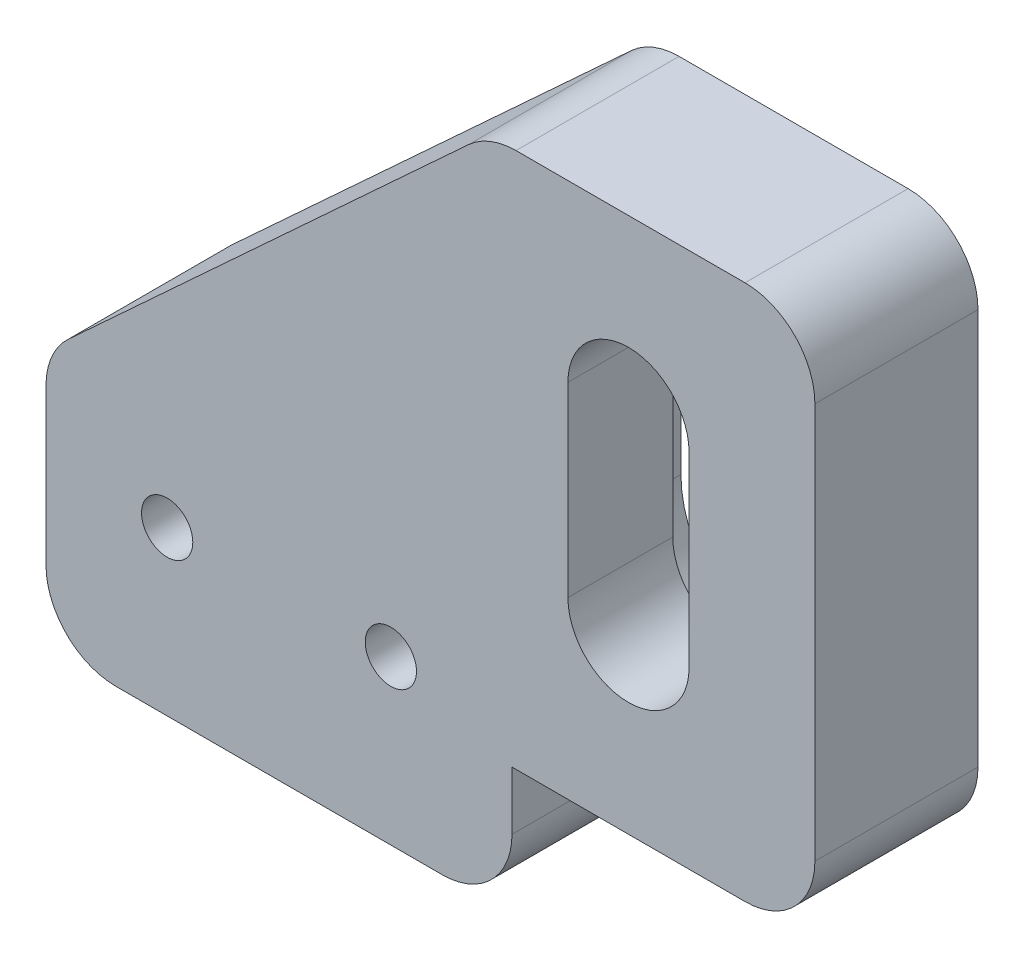
from build123d import *

# Parameters (mm, degrees)
SKETCH1_R           = 1.1
BOSS_EXTRUDE1_DEPTH = 7
CUT_EXTRUDE1_DEPTH  = 2.5


with BuildPart() as part:
    # Sketch1 → Boss-Extrude1 (new body)
    with BuildSketch(Plane.XY):
        with BuildLine():
            Line((3, 0), (17, 0))
            ThreePointArc((17, 0), (19.121320344, 0.878679656), (20, 3))
            Line((20, 3), (20, 5.5))
            Line((20, 5.5), (30, 5.5))
            ThreePointArc((30, 5.5), (32.121320344, 6.378679656), (33, 8.5))
            Line((33, 8.5), (33, 25.5))
            ThreePointArc((33, 25.5), (32.121320344, 27.621320344), (30, 28.5))
            Line((30, 28.5), (20.171059892, 28.5))
            ThreePointArc((20.171059892, 28.5), (19.080167127, 28.294629309), (18.138632628, 27.706635315))
            Line((18.138632628, 27.706635315), (0.967572736, 11.891185415))
            ThreePointArc((0.967572736, 11.891185415), (0.252520993, 10.889273762), (0, 9.684550099))
            Line((0, 9.684550099), (0, 3))
            ThreePointArc((0, 3), (0.878679656, 0.878679656), (3, 0))
        make_face()
        with Locations((5.2, 7)):
            Circle(SKETCH1_R, mode=Mode.SUBTRACT)
        with Locations((14.8, 7)):
            Circle(SKETCH1_R, mode=Mode.SUBTRACT)
        with BuildLine():
            Line((27.6, 21), (27.6, 13))
            ThreePointArc((27.6, 13), (25, 10.4), (22.4, 13))
            Line((22.4, 13), (22.4, 21))
            ThreePointArc((22.4, 21), (25, 23.6), (27.6, 21))
        make_face(mode=Mode.SUBTRACT)
    extrude(amount=BOSS_EXTRUDE1_DEPTH)

    # Sketch2 → Cut-Extrude1 (cut)
    with BuildSketch(Plane(origin=(0, 0, 0), x_dir=(-1, 0, 0), z_dir=(0, 0, -1))):
        with BuildLine():
            Line((-20.25, 21), (-20.25, 13))
            ThreePointArc((-20.25, 13), (-25, 8.25), (-29.75, 13))
            Line((-29.75, 13), (-29.75, 21))
            ThreePointArc((-29.75, 21), (-25, 25.75), (-20.25, 21))
        make_face()
    extrude(amount=-CUT_EXTRUDE1_DEPTH, mode=Mode.SUBTRACT)


solid = part.part
